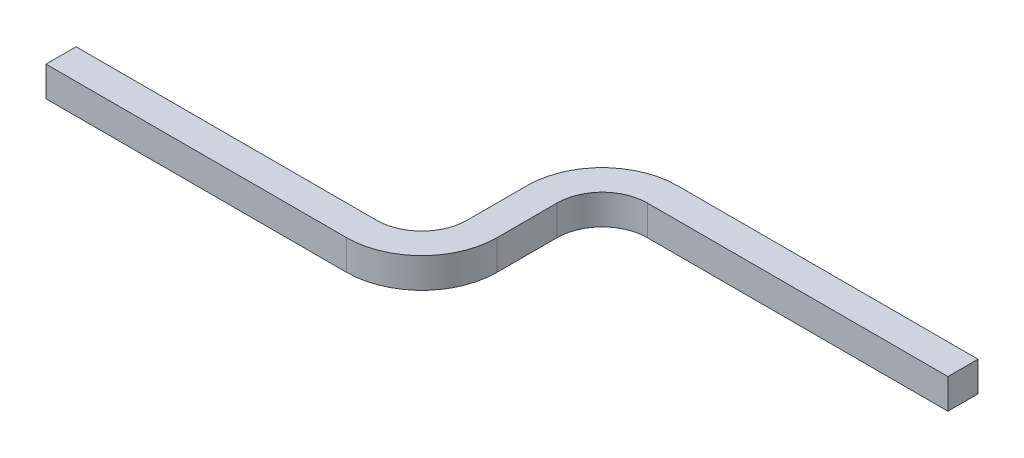
from build123d import *

# Parameters (mm, degrees)
SKETCH3_W = 10
SKETCH3_H = 10


with BuildPart() as part:
    # Sweep3: sweep along a path in Sketch1
    with BuildLine(Plane(origin=(0, 0, 0), x_dir=(1, 0, 0), z_dir=(0, 1, 0))) as sweep3_path:
        Line((0, 0), (100, 0))
        ThreePointArc((100, 0), (114.142135624, 5.857864376), (120, 20))
        Line((120, 20), (120, 40))
        ThreePointArc((120, 40), (125.857864376, 54.142135624), (140, 60))
        Line((140, 60), (240, 60))
    # Sketch3 → Sweep3 (sweep)
    with BuildSketch(Plane(origin=(0, 0, 0), x_dir=(0, 0, -1), z_dir=(1, 0, 0))):
        Rectangle(SKETCH3_W, SKETCH3_H)
    sweep(path=sweep3_path.line)


solid = part.part
